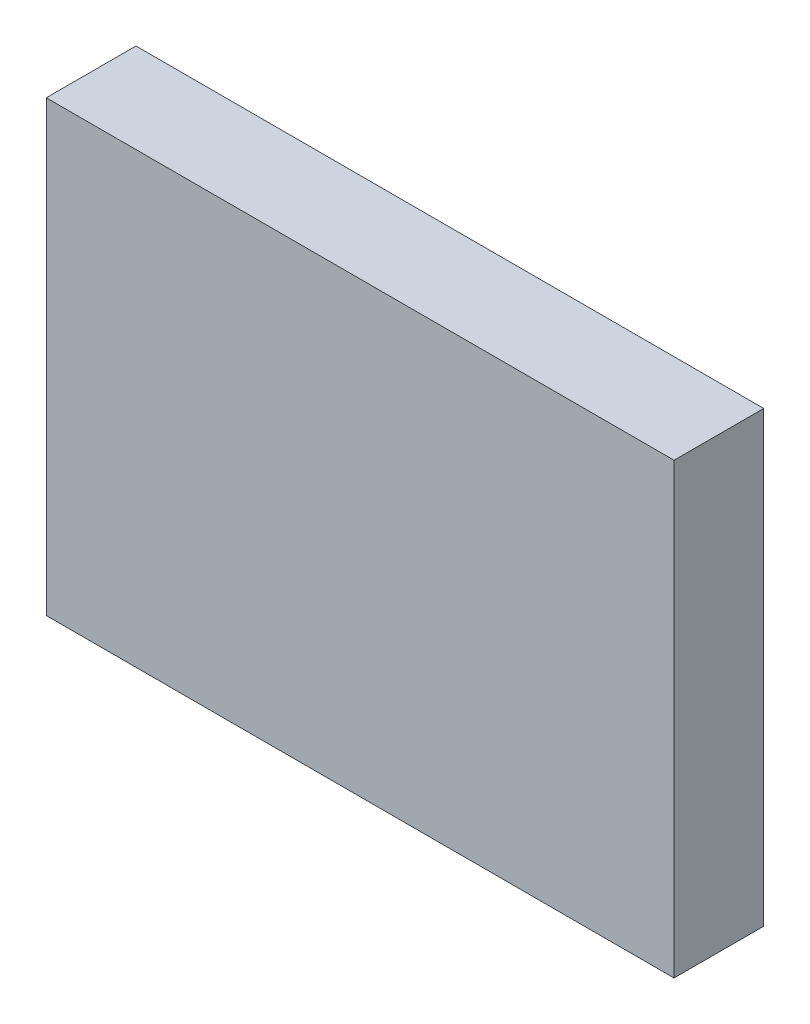
from build123d import *

# Parameters (mm, degrees)
SKETCH2_W           = 28
SKETCH2_H           = 20
BOSS_EXTRUDE1_DEPTH = 4


with BuildPart() as part:
    # Sketch2 → Boss-Extrude1 (new body)
    with BuildSketch(Plane.XY):
        with Locations((14, 10)):
            Rectangle(SKETCH2_W, SKETCH2_H)
    extrude(amount=BOSS_EXTRUDE1_DEPTH)


solid = part.part
